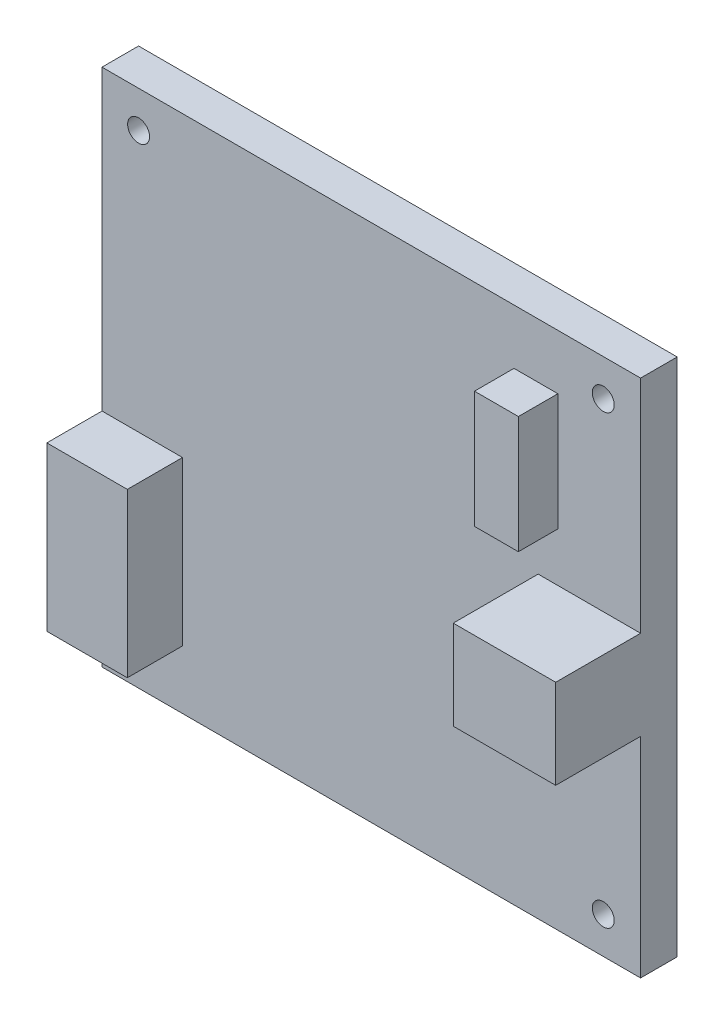
from build123d import *

# Parameters (mm, degrees)
SKETCH1_W           = 73.6
SKETCH1_H           = 71
BOSS_EXTRUDE1_DEPTH = 5
SKETCH2_R           = 1.5
CUT_EXTRUDE1_DEPTH  = 6
SKETCH3_W           = 11
SKETCH3_H           = 22.3
BOSS_EXTRUDE2_DEPTH = 7.54
SKETCH4_W           = 14
SKETCH4_H           = 12.2
BOSS_EXTRUDE3_DEPTH = 11.6
SKETCH5_W           = 6
SKETCH5_H           = 16
BOSS_EXTRUDE4_DEPTH = 5.4


with BuildPart() as part:
    # Sketch1 → Boss-Extrude1 (new body)
    with BuildSketch(Plane.XY):
        with Locations((36.8, 35.5)):
            Rectangle(SKETCH1_W, SKETCH1_H)
    extrude(amount=BOSS_EXTRUDE1_DEPTH)

    # Sketch2 → Cut-Extrude1 (cut, through all)
    with BuildSketch(Plane.XY.offset(5)):
        with Locations((5, 5)):
            Circle(SKETCH2_R)
        with Locations((68.5, 5)):
            Circle(SKETCH2_R)
        with Locations((68.5, 66)):
            Circle(SKETCH2_R)
        with Locations((5, 66)):
            Circle(SKETCH2_R)
    extrude(amount=-CUT_EXTRUDE1_DEPTH, mode=Mode.SUBTRACT)

    # Sketch3 → Boss-Extrude2 (add)
    with BuildSketch(Plane.XY.offset(5)):
        with Locations((5.5, 19.15)):
            Rectangle(SKETCH3_W, SKETCH3_H)
    extrude(amount=BOSS_EXTRUDE2_DEPTH)

    # Sketch4 → Boss-Extrude3 (add)
    with BuildSketch(Plane.XY.offset(5)):
        with Locations((66.6, 34.7)):
            Rectangle(SKETCH4_W, SKETCH4_H)
    extrude(amount=BOSS_EXTRUDE3_DEPTH)

    # Sketch5 → Boss-Extrude4 (add)
    with BuildSketch(Plane.XY.offset(5)):
        with Locations((59.3, 55.5)):
            Rectangle(SKETCH5_W, SKETCH5_H)
    extrude(amount=BOSS_EXTRUDE4_DEPTH)


solid = part.part
